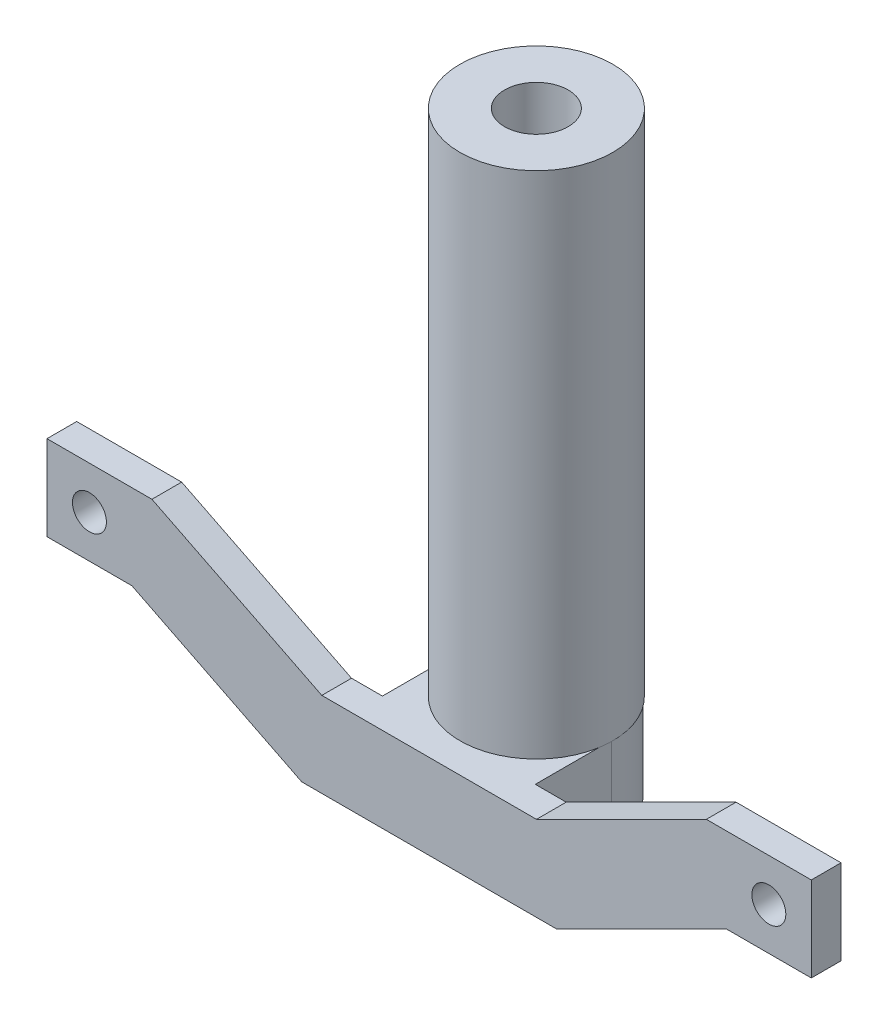
from build123d import *

# Parameters (mm, degrees)
SKETCH_1_R          = 4
EXTRUDE_1_DEPTH     = 7
SKETCH_2_W          = 36
SKETCH_2_H          = 20
EXTRUDE_2_DEPTH     = 36
SKETCH_3_R          = 7.5
CUT_EXTRUDE_2_DEPTH = 36
SKETCH_4_R          = 18
SKETCH_4_R_2        = 7.5
EXTRUDE_3_DEPTH     = 120


with BuildPart() as part:
    # 草图1 → 凸台-拉伸1 (new body)
    with BuildSketch(Plane.XY):
        Polygon((-30, 0), (30, 0), (70, 20), (90, 20), (90, 40), (65.27864045, 40), (25.27864045, 20), (-25.27864045, 20), (-65.27864045, 40), (-90, 40), (-90, 20), (-70, 20), align=None)
        with Locations((80, 30)):
            Circle(SKETCH_1_R, mode=Mode.SUBTRACT)
        with Locations((-80, 30)):
            Circle(SKETCH_1_R, mode=Mode.SUBTRACT)
    extrude(amount=EXTRUDE_1_DEPTH)

    # 草图2 → 凸台-拉伸2 (add)
    with BuildSketch(Plane(origin=(0, 0, 0), x_dir=(-1, 0, 0), z_dir=(0, 0, -1))):
        with Locations((0, 10)):
            Rectangle(SKETCH_2_W, SKETCH_2_H)
    extrude(amount=EXTRUDE_2_DEPTH)

    # 草图3 → 切除-拉伸2 (cut)
    with BuildSketch(Plane(origin=(0, 20, 0), x_dir=(1, 0, 0), z_dir=(0, 1, 0))):
        with BuildLine():
            ThreePointArc((-6.6e-08, 36), (12.727922038, 30.727922085), (18, 18))
            Line((18, 18), (18, 36))
            Line((18, 36), (-6.6e-08, 36))
        make_face()
        with BuildLine():
            Line((-18, 36), (-18, 18))
            ThreePointArc((-18, 18), (-12.727922085, 30.727922038), (-6.6e-08, 36))
            Line((-6.6e-08, 36), (-18, 36))
        make_face()
        with Locations((0.255418615, 18)):
            Circle(SKETCH_3_R)
    extrude(amount=-CUT_EXTRUDE_2_DEPTH, mode=Mode.SUBTRACT)

    # 草图4 → 凸台-拉伸3 (add)
    with BuildSketch(Plane(origin=(0, 20, 0), x_dir=(1, 0, 0), z_dir=(0, 1, 0))):
        with Locations((0.255418615, 18)):
            Circle(SKETCH_4_R)
        with Locations((0.255418615, 18)):
            Circle(SKETCH_4_R_2, mode=Mode.SUBTRACT)
    extrude(amount=EXTRUDE_3_DEPTH)


solid = part.part
